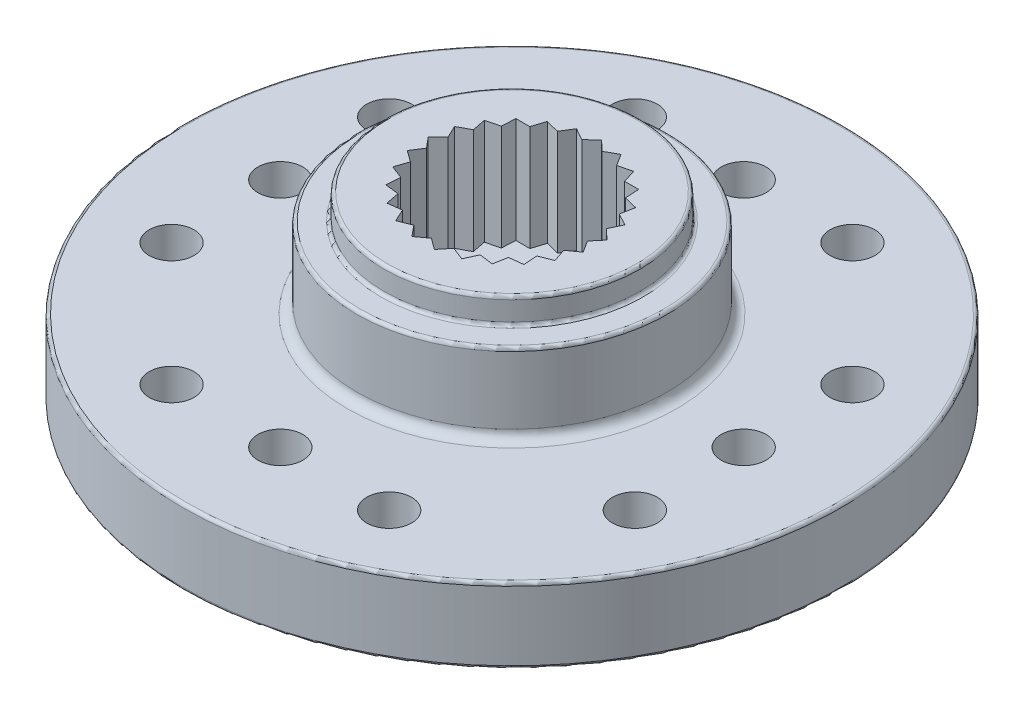
from build123d import *

# Parameters (mm, degrees)
SKETCH1_R           = 10.3
SKETCH1_R_2         = 1.39
BOSS_EXTRUDE1_DEPTH = 2.35
SKETCH2_R           = 4.85
BOSS_EXTRUDE2_DEPTH = 3.3
SKETCH3_R           = 4.85
SKETCH3_R_2         = 4
CUT_EXTRUDE1_DEPTH  = 0.8
SKETCH4_R           = 4.4
SKETCH4_R_2         = 3.35
SKETCH4_R_3         = 2.85
SKETCH4_R_4         = 1.39
CUT_EXTRUDE2_DEPTH  = 1.7
SKETCH5_R           = 0.7
CUT_EXTRUDE3_DEPTH  = 6.65
FILLET1_R           = 0.1
FILLET2_R           = 0.3


with BuildPart() as part:
    # Sketch1 → Boss-Extrude1 (new body)
    with BuildSketch(Plane(origin=(0, 0, 0), x_dir=(1, 0, 0), z_dir=(0, 1, 0))):
        Circle(SKETCH1_R)
        Circle(SKETCH1_R_2, mode=Mode.SUBTRACT)
    extrude(amount=BOSS_EXTRUDE1_DEPTH)

    # Sketch2 → Boss-Extrude2 (add)
    with BuildSketch(Plane(origin=(0, 2.35, 0), x_dir=(1, 0, 0), z_dir=(0, 1, 0))):
        Circle(SKETCH2_R)
        Polygon((0, 2.8), (-0.315823446, 2.5), (-0.696331684, 2.712032851), (-0.92762599, 2.342915806), (-1.348910287, 2.453658704), (-1.481142381, 2.038617595), (-1.916731897, 2.041112157), (-1.941593149, 1.606225543), (-2.364118191, 1.500315026), (-2.280046479, 1.072908432), (-2.662958246, 0.865247584), (-2.475236103, 0.47217654), (-2.79447484, 0.175813455), (-2.514897539, -0.158223942), (-2.750404302, -0.524667681), (-2.396538714, -0.778682631), (-2.533515747, -1.192182016), (-2.127596548, -1.350213827), (-2.15743708, -1.784787171), (-1.724969666, -1.836906122), (-1.645798706, -2.265247584), (-1.213956596, -2.20817885), (-1.030748748, -2.60337416), (-0.626666168, -2.44070358), (-0.350933054, -2.777921164), (0, -2.519869927), (0.350933054, -2.777921164), (0.626666168, -2.44070358), (1.030748748, -2.60337416), (1.213956596, -2.20817885), (1.645798706, -2.265247584), (1.724969666, -1.836906122), (2.15743708, -1.784787171), (2.127596548, -1.350213827), (2.533515747, -1.192182016), (2.396538714, -0.778682631), (2.750404302, -0.524667681), (2.514897539, -0.158223942), (2.79447484, 0.175813455), (2.475236103, 0.47217654), (2.662958246, 0.865247584), (2.280046479, 1.072908432), (2.364118191, 1.500315026), (1.941593149, 1.606225543), (1.916731897, 2.041112157), (1.481142381, 2.038617595), (1.348910287, 2.453658704), (0.92762599, 2.342915806), (0.696331684, 2.712032851), (0.315823446, 2.5), align=None, mode=Mode.SUBTRACT)
    extrude(amount=BOSS_EXTRUDE2_DEPTH)

    # Sketch3 → Cut-Extrude1 (cut)
    with BuildSketch(Plane(origin=(0, 5.65, 0), x_dir=(1, 0, 0), z_dir=(0, 1, 0))):
        Circle(SKETCH3_R)
        Circle(SKETCH3_R_2, mode=Mode.SUBTRACT)
    extrude(amount=-CUT_EXTRUDE1_DEPTH, mode=Mode.SUBTRACT)

    # Sketch4 → Cut-Extrude2 (cut)
    with BuildSketch(Plane(origin=(0, 0, 0), x_dir=(-1, 0, 0), z_dir=(0, -1, 0))):
        Circle(SKETCH4_R)
        Circle(SKETCH4_R_2, mode=Mode.SUBTRACT)
        Circle(SKETCH4_R_3)
        Circle(SKETCH4_R_4, mode=Mode.SUBTRACT)
    extrude(amount=-CUT_EXTRUDE2_DEPTH, mode=Mode.SUBTRACT)

    # Sketch5 → Cut-Extrude3 (cut, through all)
    with BuildSketch(Plane.XZ):
        with Locations((0, 7.24)):
            Circle(SKETCH5_R)
        with Locations((3.4, 7.24)):
            Circle(SKETCH5_R)
        with Locations((-3.4, 7.24)):
            Circle(SKETCH5_R)
        with Locations((7.24, 0)):
            Circle(SKETCH5_R)
        with Locations((7.24, -3.4)):
            Circle(SKETCH5_R)
        with Locations((7.24, 3.4)):
            Circle(SKETCH5_R)
        with Locations((0, -7.24)):
            Circle(SKETCH5_R)
        with Locations((-3.4, -7.24)):
            Circle(SKETCH5_R)
        with Locations((3.4, -7.24)):
            Circle(SKETCH5_R)
        with Locations((-7.24, 0)):
            Circle(SKETCH5_R)
        with Locations((-7.24, 3.4)):
            Circle(SKETCH5_R)
        with Locations((-7.24, -3.4)):
            Circle(SKETCH5_R)
    extrude(amount=-CUT_EXTRUDE3_DEPTH, mode=Mode.SUBTRACT)

    # Fillet1
    fillet1_edges = [part.edges().sort_by_distance(p)[0] for p in [
        (-4.85, 4.85, 0),
        (-4, 4.85, 0),
        (-4, 5.65, 0),
        (-10.3, 0, 0),
        (-10.3, 2.35, 0),
    ]]
    fillet(fillet1_edges, radius=FILLET1_R)

    # Fillet2
    fillet2_edges = [part.edges().sort_by_distance(p)[0] for p in [
        (-4.85, 2.35, 0),
    ]]
    fillet(fillet2_edges, radius=FILLET2_R)


solid = part.part
